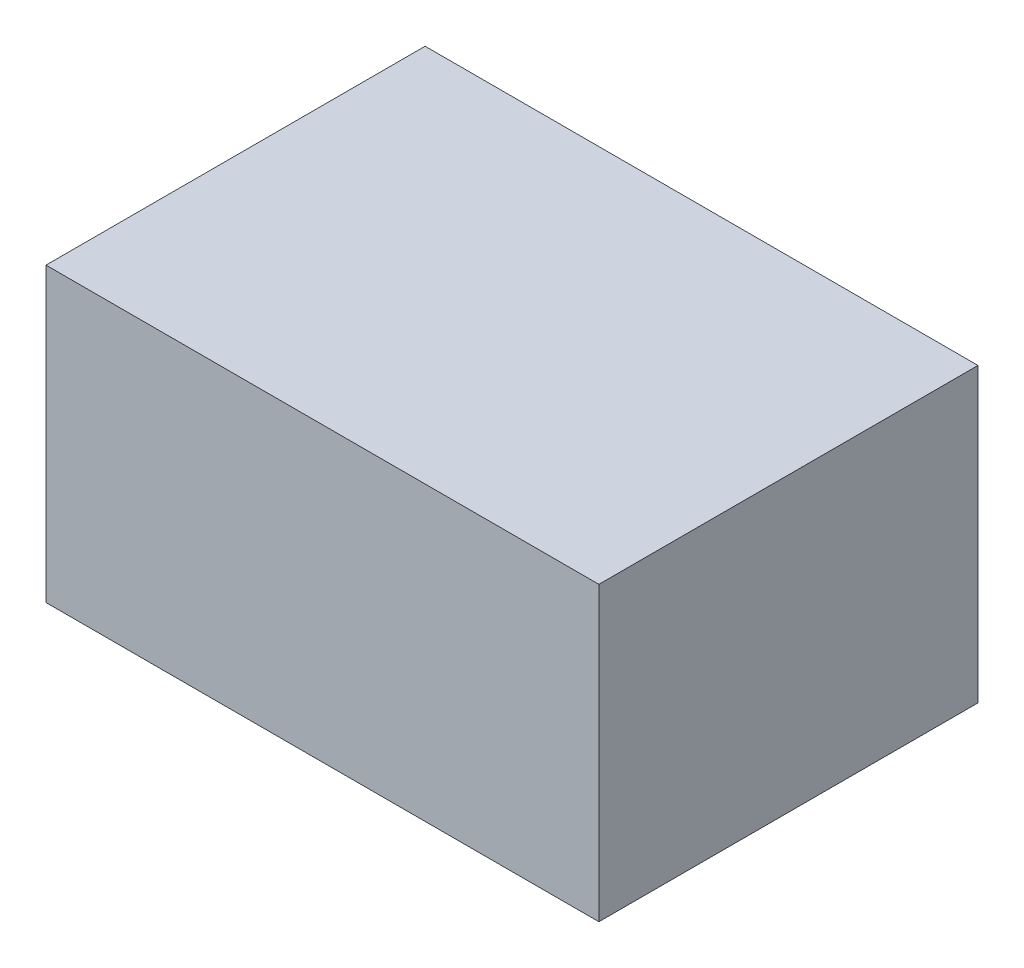
from build123d import *

# Parameters (mm, degrees)
SKETCH_1_W      = 35
SKETCH_1_H      = 18.5
EXTRUDE_1_DEPTH = 24


with BuildPart() as part:
    # 草图1 → 凸台-拉伸1 (new body)
    with BuildSketch(Plane.XY):
        with Locations((29.215194166, 13.796162455)):
            Rectangle(SKETCH_1_W, SKETCH_1_H)
    extrude(amount=EXTRUDE_1_DEPTH)


solid = part.part
